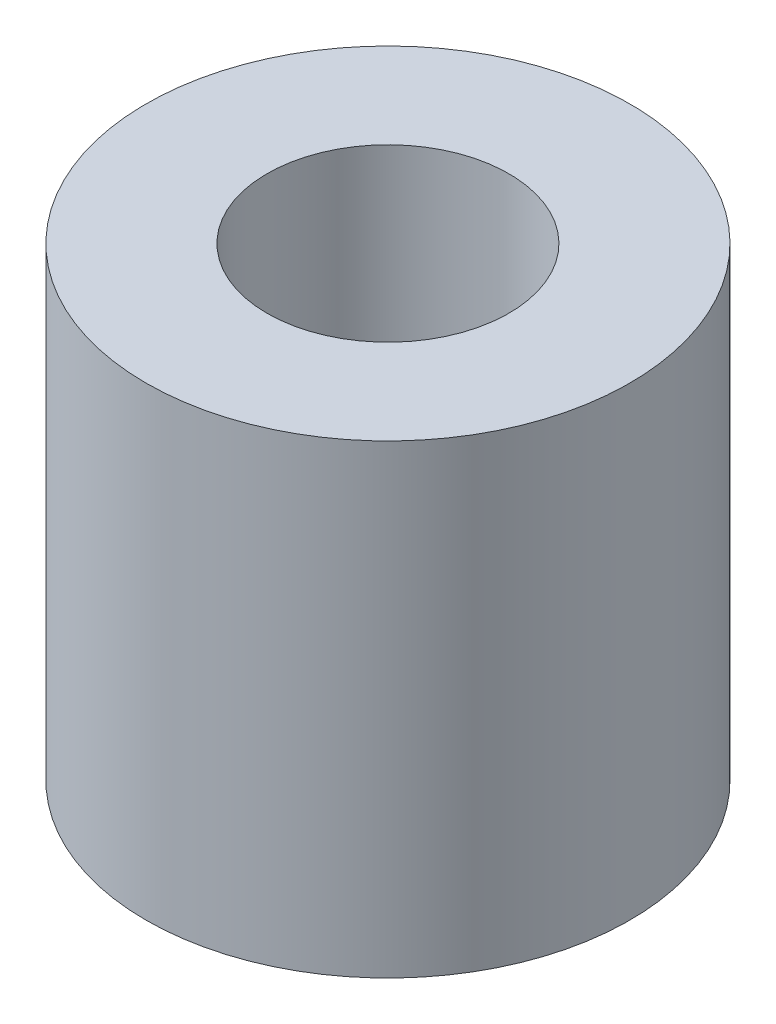
from build123d import *

# Parameters (mm, degrees)
SKETCH1_R           = 6.604
SKETCH1_R_2         = 3.302
BOSS_EXTRUDE1_DEPTH = 12.7


with BuildPart() as part:
    # Sketch1 → Boss-Extrude1 (new body)
    with BuildSketch(Plane(origin=(0, 0, 0), x_dir=(1, 0, 0), z_dir=(0, 1, 0))):
        Circle(SKETCH1_R)
        Circle(SKETCH1_R_2, mode=Mode.SUBTRACT)
    extrude(amount=BOSS_EXTRUDE1_DEPTH)


solid = part.part
